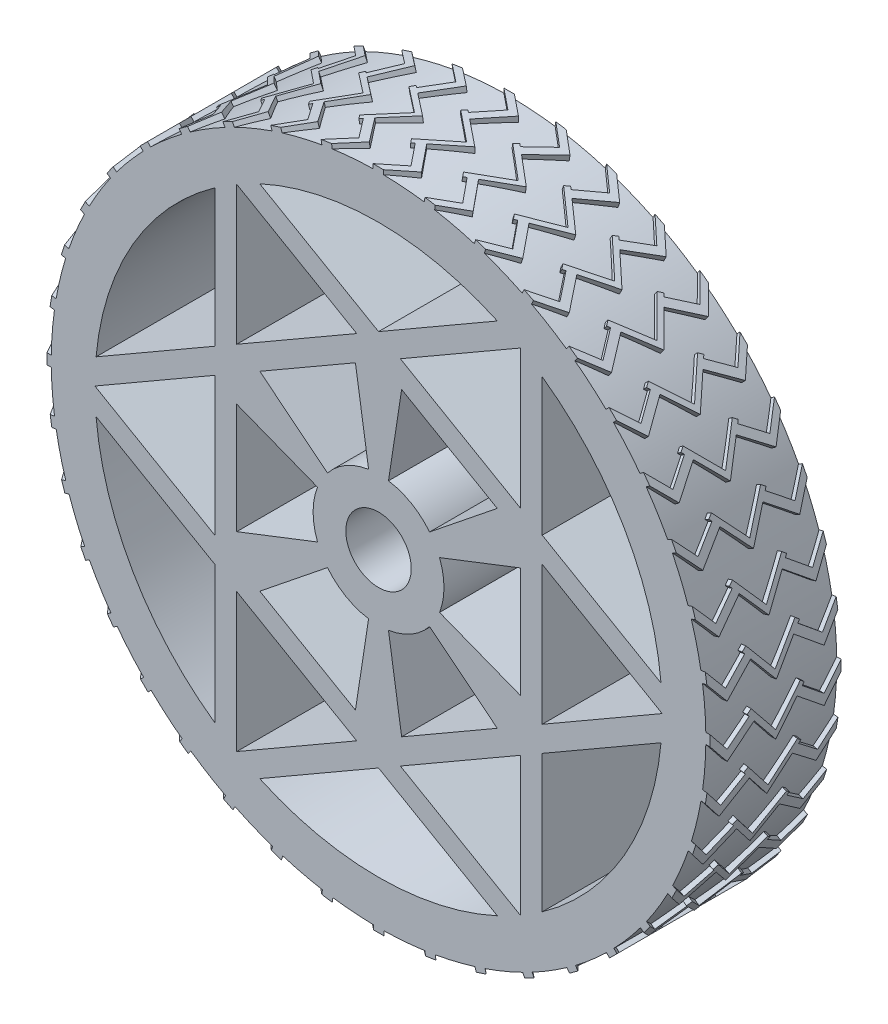
from build123d import *

# Parameters (mm, degrees)
CROQUIS1_R              = 75
SALIENTE_EXTRUIR1_DEPTH = 15
CROQUIS2_R              = 15
SALIENTE_EXTRUIR2_DEPTH = 15
SALIENTE_EXTRUIR3_DEPTH = 15
CROQUIS4_R              = 7.5
CORTAR_EXTRUIR1_DEPTH   = 30
SALIENTE_EXTRUIR4_DEPTH = 1
MATRIZC1_COUNT          = 40


with BuildPart() as part:
    # Croquis1 → Saliente-Extruir1 (new body, symmetric)
    with BuildSketch(Plane.XY):
        Circle(CROQUIS1_R)
        with BuildLine():
            Line((64.728935394, 5.930001915), (37.5, 21.650635095))
            Line((37.5, 21.650635095), (37.5, 53.091901454))
            ThreePointArc((37.5, 53.091901454), (56.291651246, 32.5), (64.728935394, 5.930001915))
        make_face(mode=Mode.SUBTRACT)
        with BuildLine():
            Line((-37.5, 53.091901454), (-37.5, 21.650635095))
            Line((-37.5, 21.650635095), (-64.728935394, 5.930001915))
            ThreePointArc((-64.728935394, 5.930001915), (-56.291651246, 32.5), (-37.5, 53.091901454))
        make_face(mode=Mode.SUBTRACT)
        with BuildLine():
            Line((-27.228935394, -59.021903369), (0, -43.301270189))
            Line((0, -43.301270189), (27.228935394, -59.021903369))
            ThreePointArc((27.228935394, -59.021903369), (0, -65), (-27.228935394, -59.021903369))
        make_face(mode=Mode.SUBTRACT)
        Polygon((-37.5, 15.877132403), (-37.5, -15.877132403), (-65, 0), align=None, mode=Mode.SUBTRACT)
        with BuildLine():
            Line((27.228935394, 59.021903369), (0, 43.301270189))
            Line((0, 43.301270189), (-27.228935394, 59.021903369))
            ThreePointArc((-27.228935394, 59.021903369), (0, 65), (27.228935394, 59.021903369))
        make_face(mode=Mode.SUBTRACT)
        with BuildLine():
            Line((-64.728935394, -5.930001915), (-37.5, -21.650635095))
            Line((-37.5, -21.650635095), (-37.5, -53.091901454))
            ThreePointArc((-37.5, -53.091901454), (-56.291651246, -32.5), (-64.728935394, -5.930001915))
        make_face(mode=Mode.SUBTRACT)
        with BuildLine():
            Line((37.5, -53.091901454), (37.5, -21.650635095))
            Line((37.5, -21.650635095), (64.728935394, -5.930001915))
            ThreePointArc((64.728935394, -5.930001915), (56.291651246, -32.5), (37.5, -53.091901454))
        make_face(mode=Mode.SUBTRACT)
        Polygon((32.5, 56.291651246), (5, 40.414518843), (32.5, 24.537386441), align=None, mode=Mode.SUBTRACT)
        Polygon((32.5, -56.291651246), (32.5, -24.537386441), (5, -40.414518843), align=None, mode=Mode.SUBTRACT)
        Polygon((65, 0), (37.5, 15.877132403), (37.5, -15.877132403), align=None, mode=Mode.SUBTRACT)
        Polygon((-32.5, 56.291651246), (-32.5, 24.537386441), (-5, 40.414518843), align=None, mode=Mode.SUBTRACT)
        Polygon((-32.5, -56.291651246), (-5, -40.414518843), (-32.5, -24.537386441), align=None, mode=Mode.SUBTRACT)
        Polygon((-32.5, 18.763883749), (-32.5, -18.763883749), (0, -37.527767497), (32.5, -18.763883749), (32.5, 18.763883749), (0, 37.527767497), align=None, mode=Mode.SUBTRACT)
    extrude(amount=SALIENTE_EXTRUIR1_DEPTH, both=True)



with BuildPart() as body_2:
    # Croquis2 → Saliente-Extruir2 (new body, symmetric)
    with BuildSketch(Plane.XY):
        Circle(CROQUIS2_R)
    extrude(amount=SALIENTE_EXTRUIR2_DEPTH, both=True)


with BuildPart() as part_1:
    add(part.part)

    add(body_2.part)  # Saliente-Extruir3 merges body 2
    # Croquis3 → Saliente-Extruir3 (add, symmetric)
    with BuildSketch(Plane.XY):
        Polygon((0, 0), (5.293497426, 34.471565334), (0, 37.527767497), (-5.293497426, 34.471565334), align=None)
        Polygon((0, 0), (-27.206502574, 21.820085912), (-32.5, 18.763883749), (-32.5, 12.651479421), align=None)
        Polygon((0, 0), (-32.5, -12.651479421), (-32.5, -18.763883749), (-27.206502574, -21.820085912), align=None)
        Polygon((0, 0), (-5.293497426, -34.471565334), (0, -37.527767497), (5.293497426, -34.471565334), align=None)
        Polygon((0, 0), (27.206502574, -21.820085912), (32.5, -18.763883749), (32.5, -12.651479421), align=None)
        Polygon((32.5, 12.651479421), (32.5, 18.763883749), (27.206502574, 21.820085912), (0, 0), align=None)
    extrude(amount=SALIENTE_EXTRUIR3_DEPTH, both=True)

    # Croquis4 → Cortar-Extruir1 (cut)
    with BuildSketch(Plane(origin=(0, 0, -15), x_dir=(-1, 0, 0), z_dir=(0, 0, -1))):
        Circle(CROQUIS4_R)
    extrude(amount=-CORTAR_EXTRUIR1_DEPTH, mode=Mode.SUBTRACT)

    # Croquis6 → Saliente-Extruir4 (add, symmetric)
    with BuildSketch(Plane.ZY.offset(75)):
        Polygon((0, 5.184059731), (-5.64130429, -1.803313957), (-6.557262979, -1.063808398), (-6.099283634, -0.496550782), (-11.104078278, 3.544104656), (-15, -1.281421416), (-15, 1.13134162), (-11.104078278, 5.956867692), (-4.920005753, 0.964114131), (0, 7.058080523), (4.920005753, 0.964114131), (11.104078278, 5.956867692), (15, 1.13134162), (15, -1.281421416), (11.104078278, 3.544104656), (6.099283634, -0.496550782), (6.557262979, -1.063808398), (5.64130429, -1.803313957), align=None)
    saliente_extruir4 = extrude(amount=SALIENTE_EXTRUIR4_DEPTH, both=True)

    # MatrizC1: Saliente-Extruir4 ×40 about axis
    matrizc1_axis = Axis((0, 0, 0), (0, 0, 1))
    for i in range(1, MATRIZC1_COUNT):
        add(saliente_extruir4.rotate(matrizc1_axis, i * 360 / MATRIZC1_COUNT))


solid = part_1.part
